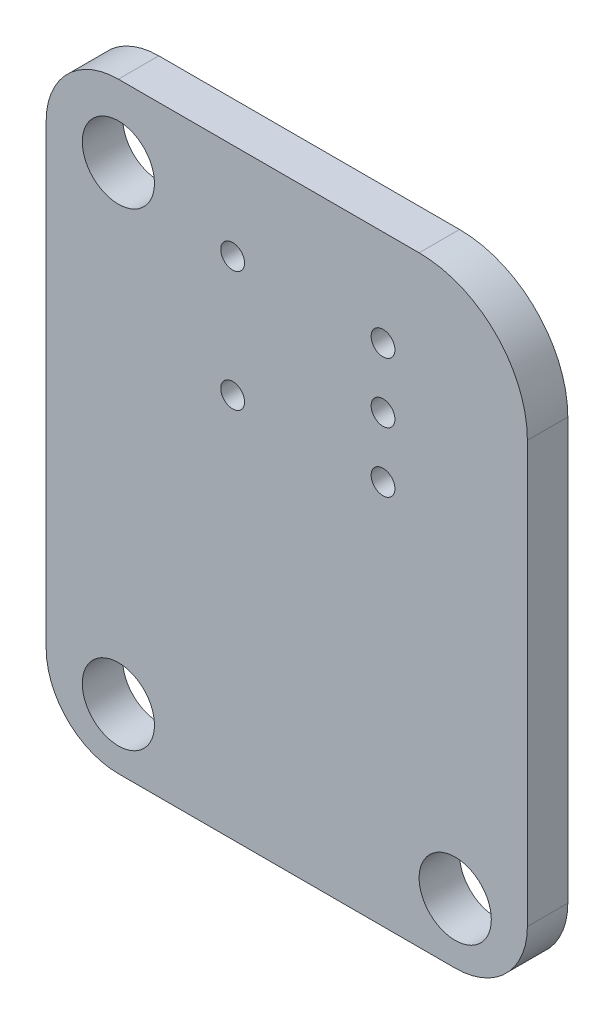
from build123d import *

# Parameters (mm, degrees)
BOARD_DEPTH        = 1.68
SKETCH2_R          = 1.5
SKETCH2_R_2        = 0.4953
PLATED_HOLES_DEPTH = 5.7


with BuildPart() as part:
    # Sketch1 → BOARD (new body)
    with BuildSketch(Plane.XY.offset(-4.7)):
        with BuildLine():
            Line((100, 43), (100, 60.5))
            ThreePointArc((100, 60.5), (98.681980515, 63.681980515), (95.5, 65))
            Line((95.5, 65), (83, 65))
            ThreePointArc((83, 65), (80.878679656, 64.121320344), (80, 62))
            Line((80, 62), (80, 43))
            ThreePointArc((80, 43), (80.878679656, 40.878679656), (83, 40))
            Line((83, 40), (97, 40))
            ThreePointArc((97, 40), (99.121320344, 40.878679656), (100, 43))
        make_face()
    extrude(amount=BOARD_DEPTH)

    # Sketch2 → PLATED HOLES (cut, through all)
    with BuildSketch(Plane.XY):
        with Locations((83, 42.5)):
            Circle(SKETCH2_R)
        with Locations((97, 42.5)):
            Circle(SKETCH2_R)
        with Locations((97, 35.5)):
            Circle(SKETCH2_R)
        with Locations((83, 62)):
            Circle(SKETCH2_R)
        with Locations((87.749999989, 55.999999989)):
            Circle(SKETCH2_R_2)
        with Locations((87.749999989, 60.999999996)):
            Circle(SKETCH2_R_2)
        with Locations((94.000000011, 58.499999992)):
            Circle(SKETCH2_R_2)
        with Locations((94.000000011, 55.999999989)):
            Circle(SKETCH2_R_2)
        with Locations((94.000000011, 60.999999996)):
            Circle(SKETCH2_R_2)
    extrude(amount=-PLATED_HOLES_DEPTH, mode=Mode.SUBTRACT)


solid = part.part
